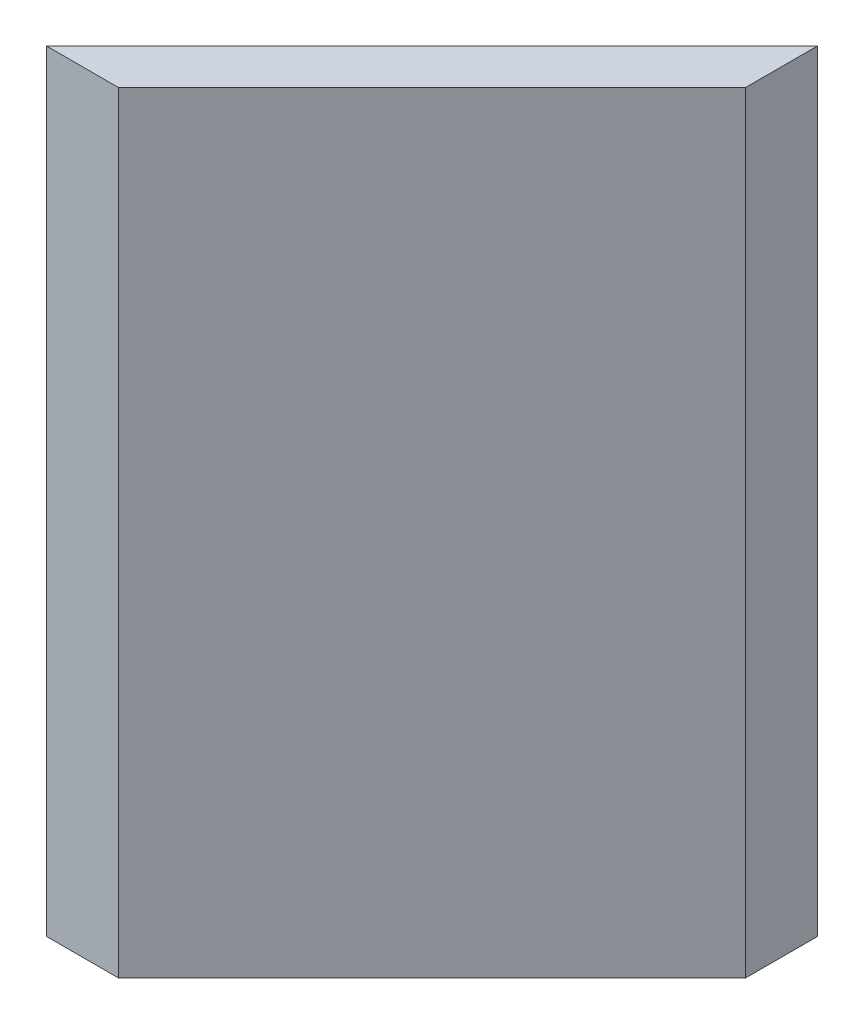
from build123d import *

# Parameters (mm, degrees)
BOSS_EXTRUDE1_DEPTH = 182


with BuildPart() as part:
    # Sketch1 → Boss-Extrude1 (new body)
    with BuildSketch(Plane(origin=(0, 0, 0), x_dir=(1, 0, 0), z_dir=(0, 1, 0))):
        Polygon((-74, 0), (0, 74), (0, 90.970562748), (-90.970562748, 0), align=None)
    extrude(amount=BOSS_EXTRUDE1_DEPTH)


solid = part.part
